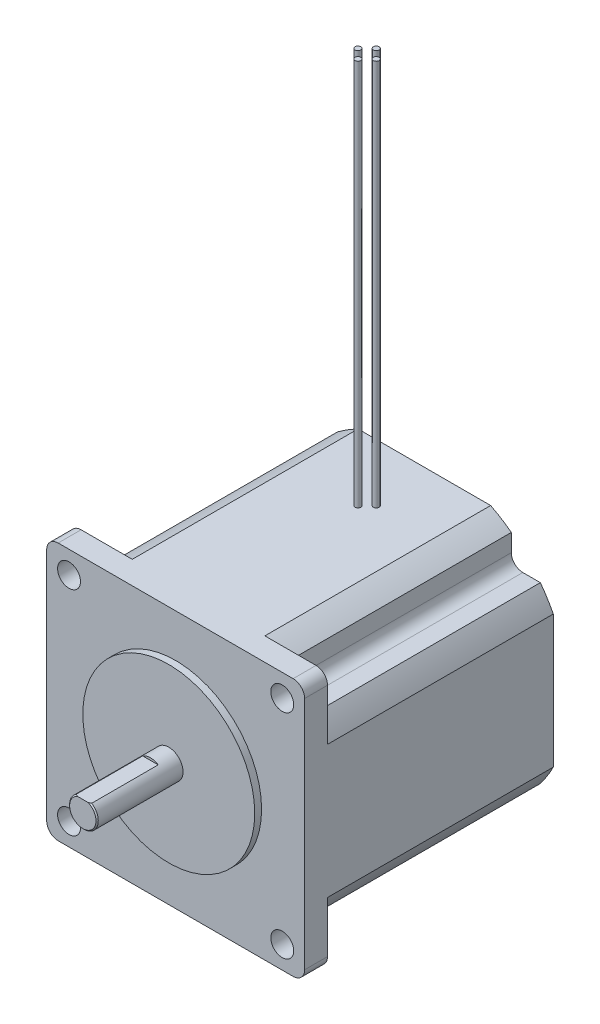
from build123d import *

# Parameters (mm, degrees)
SKETCH1_W           = 57.15
SKETCH1_H           = 57.15
BOSS_EXTRUDE1_DEPTH = 55.118
CUT_EXTRUDE1_DEPTH  = 50.038
CUT_EXTRUDE2_DEPTH  = 50.038
CUT_EXTRUDE3_DEPTH  = 50.038
CUT_EXTRUDE4_DEPTH  = 50.038
CUT_EXTRUDE5_DEPTH  = 50.038
CUT_EXTRUDE6_DEPTH  = 50.038
CUT_EXTRUDE7_DEPTH  = 50.038
CUT_EXTRUDE8_DEPTH  = 50.038
SKETCH10_R          = 19.05
BOSS_EXTRUDE2_DEPTH = 1.524
SKETCH11_R          = 3.175
BOSS_EXTRUDE3_DEPTH = 19.05
CUT_EXTRUDE9_DEPTH  = 14.986
SKETCH13_W          = 0.635
SKETCH13_H          = 85.725
SKETCH14_W          = 0.635
SKETCH14_H          = 85.725
SKETCH15_W          = 0.635
SKETCH15_H          = 85.725
SKETCH16_W          = 0.635
SKETCH16_H          = 85.725
HOLE1_D             = 5.08
HOLE1_DEPTH         = 25.654
HOLE2_D             = 5.08
HOLE2_DEPTH         = 25.654
HOLE3_D             = 5.08
HOLE3_DEPTH         = 25.654
HOLE4_D             = 5.08
HOLE4_DEPTH         = 25.654
CHAMFER1_SIZE       = 0.254
FILLET1_R           = 2.54
FILLET2_R           = 2.54
FILLET3_R           = 2.54
FILLET4_R           = 2.54
FILLET5_R           = 2.54
FILLET6_R           = 2.54
FILLET7_R           = 2.54
FILLET8_R           = 2.54


with BuildPart() as part:
    # Sketch1 → Boss-Extrude1 (new body)
    with BuildSketch(Plane.XY.offset(55.118)):
        Rectangle(SKETCH1_W, SKETCH1_H)
    extrude(amount=-BOSS_EXTRUDE1_DEPTH)

    # Sketch2 → Cut-Extrude1 (cut)
    with BuildSketch(Plane(origin=(0, 0, 0), x_dir=(-1, 0, 0), z_dir=(0, 0, -1))):
        with BuildLine():
            Line((-28.575, -28.575), (-14.692533342, -28.575))
            ThreePointArc((-14.692533342, -28.575), (-22.720047986, -22.720047986), (-28.575, -14.692533342))
            Line((-28.575, -14.692533342), (-28.575, -28.575))
        make_face()
    extrude(amount=-CUT_EXTRUDE1_DEPTH, mode=Mode.SUBTRACT)

    # Sketch3 → Cut-Extrude2 (cut)
    with BuildSketch(Plane(origin=(0, 0, 0), x_dir=(-1, 0, 0), z_dir=(0, 0, -1))):
        with BuildLine():
            Line((-19.2786, -25.7048), (-19.2786, -19.2786))
            Line((-19.2786, -19.2786), (-25.7048, -19.2786))
            ThreePointArc((-25.7048, -19.2786), (-22.720047986, -22.720047986), (-19.2786, -25.7048))
        make_face()
    extrude(amount=-CUT_EXTRUDE2_DEPTH, mode=Mode.SUBTRACT)

    # Sketch4 → Cut-Extrude3 (cut)
    with BuildSketch(Plane(origin=(0, 0, 0), x_dir=(-1, 0, 0), z_dir=(0, 0, -1))):
        with BuildLine():
            Line((-28.575, 28.575), (-28.575, 14.692533342))
            ThreePointArc((-28.575, 14.692533342), (-22.720047986, 22.720047986), (-14.692533342, 28.575))
            Line((-14.692533342, 28.575), (-28.575, 28.575))
        make_face()
    extrude(amount=-CUT_EXTRUDE3_DEPTH, mode=Mode.SUBTRACT)

    # Sketch5 → Cut-Extrude4 (cut)
    with BuildSketch(Plane(origin=(0, 0, 0), x_dir=(-1, 0, 0), z_dir=(0, 0, -1))):
        with BuildLine():
            Line((-25.7048, 19.2786), (-19.2786, 19.2786))
            Line((-19.2786, 19.2786), (-19.2786, 25.7048))
            ThreePointArc((-19.2786, 25.7048), (-22.720047986, 22.720047986), (-25.7048, 19.2786))
        make_face()
    extrude(amount=-CUT_EXTRUDE4_DEPTH, mode=Mode.SUBTRACT)

    # Sketch6 → Cut-Extrude5 (cut)
    with BuildSketch(Plane(origin=(0, 0, 0), x_dir=(-1, 0, 0), z_dir=(0, 0, -1))):
        with BuildLine():
            Line((28.575, 28.575), (14.692533342, 28.575))
            ThreePointArc((14.692533342, 28.575), (22.720047986, 22.720047986), (28.575, 14.692533342))
            Line((28.575, 14.692533342), (28.575, 28.575))
        make_face()
    extrude(amount=-CUT_EXTRUDE5_DEPTH, mode=Mode.SUBTRACT)

    # Sketch7 → Cut-Extrude6 (cut)
    with BuildSketch(Plane(origin=(0, 0, 0), x_dir=(-1, 0, 0), z_dir=(0, 0, -1))):
        with BuildLine():
            Line((19.2786, 25.7048), (19.2786, 19.2786))
            Line((19.2786, 19.2786), (25.7048, 19.2786))
            ThreePointArc((25.7048, 19.2786), (22.720047986, 22.720047986), (19.2786, 25.7048))
        make_face()
    extrude(amount=-CUT_EXTRUDE6_DEPTH, mode=Mode.SUBTRACT)

    # Sketch8 → Cut-Extrude7 (cut)
    with BuildSketch(Plane(origin=(0, 0, 0), x_dir=(-1, 0, 0), z_dir=(0, 0, -1))):
        with BuildLine():
            Line((28.575, -28.575), (28.575, -14.692533342))
            ThreePointArc((28.575, -14.692533342), (22.720047986, -22.720047986), (14.692533342, -28.575))
            Line((14.692533342, -28.575), (28.575, -28.575))
        make_face()
    extrude(amount=-CUT_EXTRUDE7_DEPTH, mode=Mode.SUBTRACT)

    # Sketch9 → Cut-Extrude8 (cut)
    with BuildSketch(Plane(origin=(0, 0, 0), x_dir=(-1, 0, 0), z_dir=(0, 0, -1))):
        with BuildLine():
            Line((25.7048, -19.2786), (19.2786, -19.2786))
            Line((19.2786, -19.2786), (19.2786, -25.7048))
            ThreePointArc((19.2786, -25.7048), (22.720047986, -22.720047986), (25.7048, -19.2786))
        make_face()
    extrude(amount=-CUT_EXTRUDE8_DEPTH, mode=Mode.SUBTRACT)

    # Sketch10 → Boss-Extrude2 (add)
    with BuildSketch(Plane.XY.offset(55.118)):
        Circle(SKETCH10_R)
    extrude(amount=BOSS_EXTRUDE2_DEPTH)

    # Sketch11 → Boss-Extrude3 (add)
    with BuildSketch(Plane.XY.offset(56.642)):
        Circle(SKETCH11_R)
    extrude(amount=BOSS_EXTRUDE3_DEPTH)

    # Sketch12 → Cut-Extrude9 (cut)
    with BuildSketch(Plane.XY.offset(75.692)):
        with BuildLine():
            Line((-1.722711816, 2.667), (1.722711816, 2.667))
            ThreePointArc((1.722711816, 2.667), (0, 3.175), (-1.722711816, 2.667))
        make_face()
    extrude(amount=-CUT_EXTRUDE9_DEPTH, mode=Mode.SUBTRACT)

    # Sketch13 → Revolve1 (revolve)
    with BuildSketch(Plane(origin=(0, 0, 12.7), x_dir=(-1, 0, 0), z_dir=(0, 0, -1))):
        with Locations((1.7145, 71.4375)):
            Rectangle(SKETCH13_W, SKETCH13_H)
    revolve(axis=Axis((-2.032, 28.575, 12.7), (0, 1, 0)))

    # Sketch14 → Revolve2 (revolve)
    with BuildSketch(Plane(origin=(0, 0, 12.7), x_dir=(-1, 0, 0), z_dir=(0, 0, -1))):
        with Locations((-2.3495, 71.4375)):
            Rectangle(SKETCH14_W, SKETCH14_H)
    revolve(axis=Axis((2.032, 28.575, 12.7), (0, 1, 0)))

    # Sketch15 → Revolve3 (revolve)
    with BuildSketch(Plane(origin=(0, 0, 14.732), x_dir=(-1, 0, 0), z_dir=(0, 0, -1))):
        with Locations((-0.3175, 71.4375)):
            Rectangle(SKETCH15_W, SKETCH15_H)
    revolve(axis=Axis((0, 28.575, 14.732), (0, 1, 0)))

    # Sketch16 → Revolve4 (revolve)
    with BuildSketch(Plane(origin=(0, 0, 10.668), x_dir=(-1, 0, 0), z_dir=(0, 0, -1))):
        with Locations((-0.3175, 71.4375)):
            Rectangle(SKETCH16_W, SKETCH16_H)
    revolve(axis=Axis((0, 28.575, 10.668), (0, 1, 0)))

    # Hole1
    with Locations(Plane(origin=(0, 0, 50.038), x_dir=(-1, 0, 0), z_dir=(0, 0, -1))):
        with Locations((23.622, -23.622)):
            Hole(HOLE1_D / 2, depth=HOLE1_DEPTH)

    # Hole2
    with Locations(Plane(origin=(0, 0, 50.038), x_dir=(-1, 0, 0), z_dir=(0, 0, -1))):
        with Locations((23.622, 23.622)):
            Hole(HOLE2_D / 2, depth=HOLE2_DEPTH)

    # Hole3
    with Locations(Plane(origin=(0, 0, 50.038), x_dir=(-1, 0, 0), z_dir=(0, 0, -1))):
        with Locations((-23.622, 23.622)):
            Hole(HOLE3_D / 2, depth=HOLE3_DEPTH)

    # Hole4
    with Locations(Plane(origin=(0, 0, 50.038), x_dir=(-1, 0, 0), z_dir=(0, 0, -1))):
        with Locations((-23.622, -23.622)):
            Hole(HOLE4_D / 2, depth=HOLE4_DEPTH)

    # Chamfer1
    chamfer1_edges = [part.edges().sort_by_distance(p)[0] for p in [
        (-1.51838977, -2.78838977, 75.692),
    ]]
    chamfer(chamfer1_edges, length=CHAMFER1_SIZE)

    # Fillet1
    fillet1_edges = [part.edges().sort_by_distance(p)[0] for p in [
        (-28.575, 28.575, 52.578),
    ]]
    fillet(fillet1_edges, radius=FILLET1_R)

    # Fillet2
    fillet2_edges = [part.edges().sort_by_distance(p)[0] for p in [
        (-28.575, -28.575, 52.578),
    ]]
    fillet(fillet2_edges, radius=FILLET2_R)

    # Fillet3
    fillet3_edges = [part.edges().sort_by_distance(p)[0] for p in [
        (28.575, 28.575, 52.578),
    ]]
    fillet(fillet3_edges, radius=FILLET3_R)

    # Fillet4
    fillet4_edges = [part.edges().sort_by_distance(p)[0] for p in [
        (-19.2786, 19.2786, 25.019),
    ]]
    fillet(fillet4_edges, radius=FILLET4_R)

    # Fillet5
    fillet5_edges = [part.edges().sort_by_distance(p)[0] for p in [
        (28.575, -28.575, 52.578),
    ]]
    fillet(fillet5_edges, radius=FILLET5_R)

    # Fillet6
    fillet6_edges = [part.edges().sort_by_distance(p)[0] for p in [
        (19.2786, -19.2786, 25.019),
    ]]
    fillet(fillet6_edges, radius=FILLET6_R)

    # Fillet7
    fillet7_edges = [part.edges().sort_by_distance(p)[0] for p in [
        (19.2786, 19.2786, 25.019),
    ]]
    fillet(fillet7_edges, radius=FILLET7_R)

    # Fillet8
    fillet8_edges = [part.edges().sort_by_distance(p)[0] for p in [
        (-19.2786, -19.2786, 25.019),
    ]]
    fillet(fillet8_edges, radius=FILLET8_R)


solid = part.part
